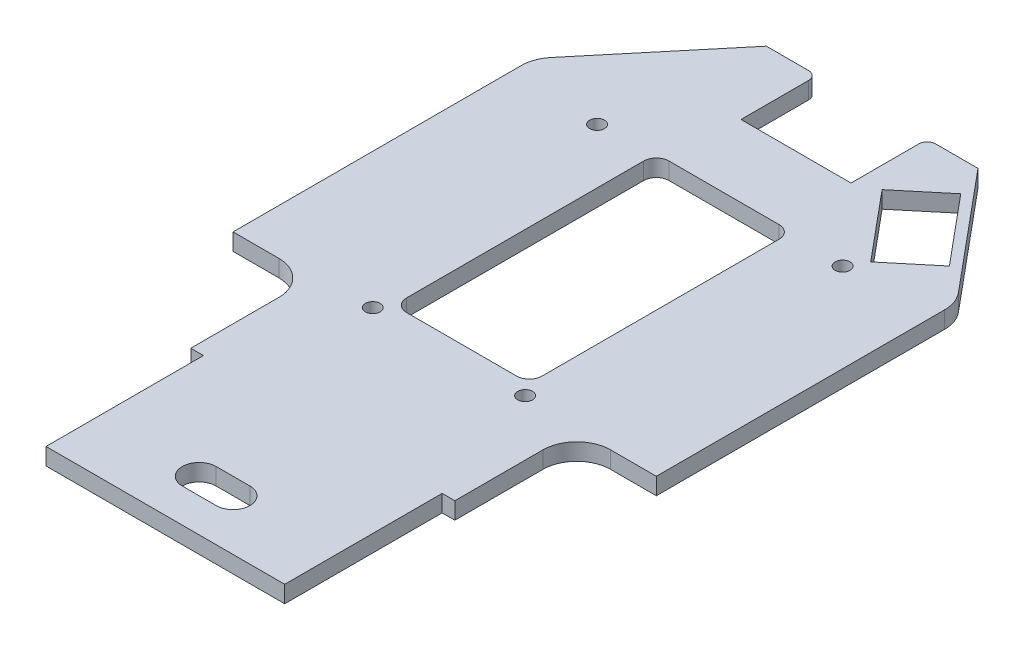
from build123d import *

# Parameters (mm, degrees)
SKETCH1_R           = 1.75
BOSS_EXTRUDE1_DEPTH = 4


with BuildPart() as part:
    # Sketch1 → Boss-Extrude1 (new body)
    with BuildSketch(Plane(origin=(0, 0, 0), x_dir=(1, 0, 0), z_dir=(0, 1, 0))):
        with BuildLine():
            Line((-28.2, -67), (28.2, -67))
            Line((28.2, -67), (28.2, -29.8))
            Line((28.2, -29.8), (31.2, -29.8))
            Line((31.2, -29.8), (31.2, -9))
            ThreePointArc((31.2, -9), (33.543145751, -3.343145751), (39.2, -1))
            Line((39.2, -1), (50, -1))
            Line((50, -1), (50, 67.103600519))
            ThreePointArc((50, 67.103600519), (49.522172621, 69.827002629), (48.145770237, 72.225075716))
            Line((48.145770237, 72.225075716), (25, 100))
            Line((25, 100), (15, 100))
            ThreePointArc((15, 100), (13.585786438, 99.414213562), (13, 98))
            Line((13, 98), (13, 82))
            Line((13, 82), (-13, 82))
            Line((-13, 82), (-13, 98))
            ThreePointArc((-13, 98), (-13.585786438, 99.414213562), (-15, 100))
            Line((-15, 100), (-25, 100))
            Line((-25, 100), (-48.145770237, 72.225075716))
            ThreePointArc((-48.145770237, 72.225075716), (-49.522172621, 69.827002629), (-50, 67.103600519))
            Line((-50, 67.103600519), (-50, -1))
            Line((-50, -1), (-39.2, -1))
            ThreePointArc((-39.2, -1), (-33.543145751, -3.343145751), (-31.2, -9))
            Line((-31.2, -9), (-31.2, -29.8))
            Line((-31.2, -29.8), (-28.2, -29.8))
            Line((-28.2, -29.8), (-28.2, -67))
        make_face()
        with Locations((18, 0)):
            Circle(SKETCH1_R, mode=Mode.SUBTRACT)
        with Locations((-18, 0)):
            Circle(SKETCH1_R, mode=Mode.SUBTRACT)
        with Locations((29, 64)):
            Circle(SKETCH1_R, mode=Mode.SUBTRACT)
        with Locations((-29, 64)):
            Circle(SKETCH1_R, mode=Mode.SUBTRACT)
        with BuildLine():
            Line((-13, 3), (13, 3))
            ThreePointArc((13, 3), (15.121320344, 3.878679656), (16, 6))
            Line((16, 6), (16, 62))
            ThreePointArc((16, 62), (15.121320344, 64.121320344), (13, 65))
            Line((13, 65), (-13, 65))
            ThreePointArc((-13, 65), (-15.121320344, 64.121320344), (-16, 62))
            Line((-16, 62), (-16, 6))
            ThreePointArc((-16, 6), (-15.121320344, 3.878679656), (-13, 3))
        make_face(mode=Mode.SUBTRACT)
        with BuildLine():
            Line((-4, -51), (4, -51))
            ThreePointArc((4, -51), (8, -55), (4, -59))
            Line((4, -59), (-4, -59))
            ThreePointArc((-4, -59), (-8, -55), (-4, -51))
        make_face(mode=Mode.SUBTRACT)
        Polygon((28.160862107, 92.770455614), (41.6047345, 76.637808743), (31.464213609, 68.187374667), (18.020341216, 84.320021539), align=None, mode=Mode.SUBTRACT)
    extrude(amount=BOSS_EXTRUDE1_DEPTH)


solid = part.part
